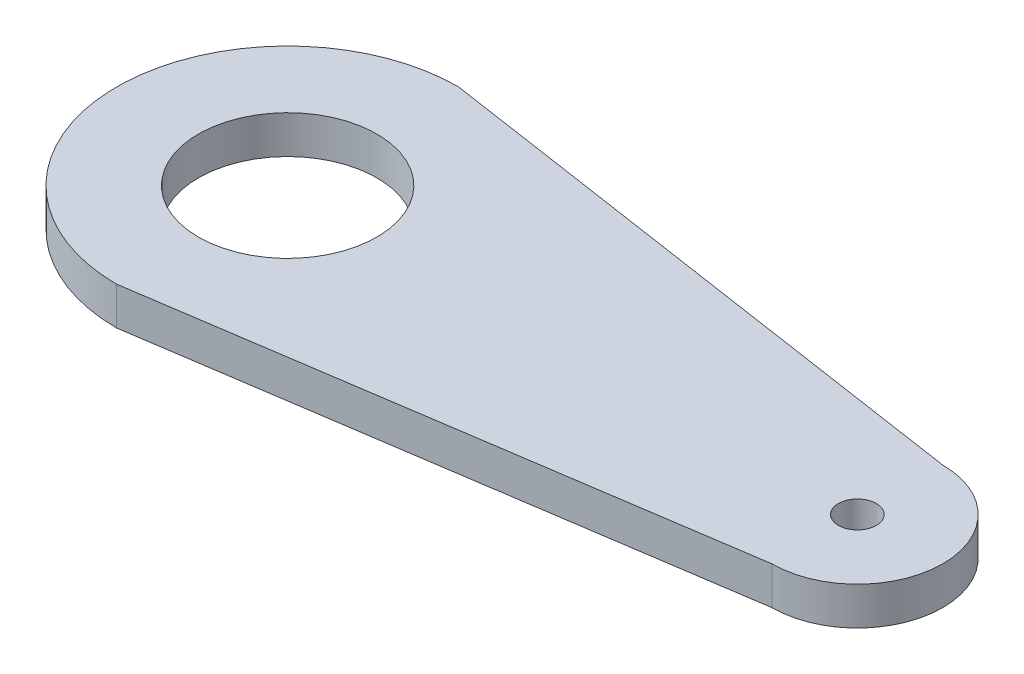
from build123d import *

# Parameters (mm, degrees)
SKETCH1_R           = 2.35
SKETCH1_R_2         = 0.5
BOSS_EXTRUDE1_DEPTH = 1


with BuildPart() as part:
    # Sketch1 → Boss-Extrude1 (new body)
    with BuildSketch(Plane(origin=(0, 0, 0), x_dir=(1, 0, 0), z_dir=(0, 1, 0))):
        with BuildLine():
            Line((1.320293399, 4.30195599), (0, 4.5))
            ThreePointArc((0, 4.5), (-4.5, 0), (0, -4.5))
            Line((0, -4.5), (1.320293399, -4.30195599))
            Line((1.320293399, -4.30195599), (15, -2.25))
            ThreePointArc((15, -2.25), (17.25, 0), (15, 2.25))
            Line((15, 2.25), (1.320293399, 4.30195599))
        make_face()
        Circle(SKETCH1_R, mode=Mode.SUBTRACT)
        with Locations((15, 0)):
            Circle(SKETCH1_R_2, mode=Mode.SUBTRACT)
    extrude(amount=BOSS_EXTRUDE1_DEPTH)


solid = part.part
